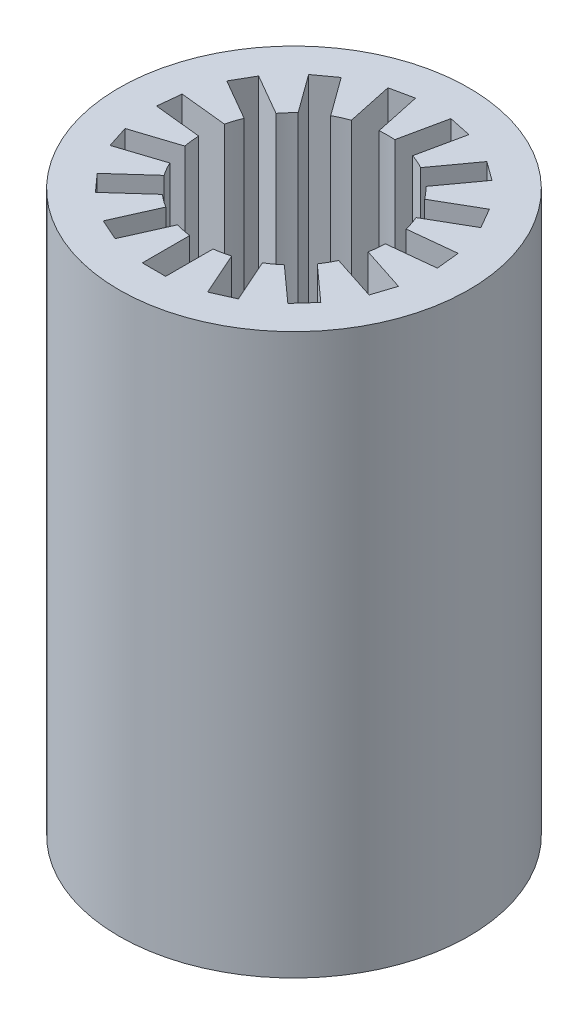
from build123d import *

# Parameters (mm, degrees)
SKETCH1_R           = 7.5
BOSS_EXTRUDE1_DEPTH = 24


with BuildPart() as part:
    # Sketch1 → Boss-Extrude1 (new body)
    with BuildSketch(Plane(origin=(0, 0, 0), x_dir=(1, 0, 0), z_dir=(0, 1, 0))):
        Circle(SKETCH1_R)
        with BuildLine():
            Line((-0.5, -3.968626967), (-0.5, -6))
            Line((-0.5, -6), (0.5, -6))
            Line((0.5, -6), (0.5, -3.968626967))
            ThreePointArc((0.5, -3.968626967), (0.831646763, -3.912590403), (1.157413281, -3.82888946))
            Line((1.157413281, -3.82888946), (1.98364713, -5.684641067))
            Line((1.98364713, -5.684641067), (2.897192587, -5.277904424))
            Line((2.897192587, -5.277904424), (2.070958739, -3.422152817))
            ThreePointArc((2.070958739, -3.422152817), (2.351141009, -3.236067977), (2.614699291, -3.027102181))
            Line((2.614699291, -3.027102181), (4.12430365, -4.386356051))
            Line((4.12430365, -4.386356051), (4.793434256, -3.643211225))
            Line((4.793434256, -3.643211225), (3.283829898, -2.283957356))
            ThreePointArc((3.283829898, -2.283957356), (3.464101615, -2), (3.61988004, -1.701901435))
            Line((3.61988004, -1.701901435), (5.551830601, -2.329630224))
            Line((5.551830601, -2.329630224), (5.860847595, -1.378573708))
            Line((5.860847595, -1.378573708), (3.928897035, -0.750844919))
            ThreePointArc((3.928897035, -0.750844919), (3.978087581, -0.418113853), (3.999150644, -0.08242647))
            Line((3.999150644, -0.08242647), (6.019395604, 0.129909832))
            Line((6.019395604, 0.129909832), (5.914867141, 1.124431727))
            Line((5.914867141, 1.124431727), (3.894622181, 0.912095426))
            ThreePointArc((3.894622181, 0.912095426), (3.804226065, 1.236067977), (3.686931771, 1.551300781))
            Line((3.686931771, 1.551300781), (5.446152423, 2.566987298))
            Line((5.446152423, 2.566987298), (4.946152423, 3.433012702))
            Line((4.946152423, 3.433012702), (3.186931771, 2.417326185))
            ThreePointArc((3.186931771, 2.417326185), (2.972579302, 2.676522425), (2.7372089, 2.916794034))
            Line((2.7372089, 2.916794034), (3.931220011, 4.56020934))
            Line((3.931220011, 4.56020934), (3.122203017, 5.147994592))
            Line((3.122203017, 5.147994592), (1.928191906, 3.504579286))
            ThreePointArc((1.928191906, 3.504579286), (1.626946572, 3.654181831), (1.314197743, 3.7779471))
            Line((1.314197743, 3.7779471), (1.736543945, 5.764929759))
            Line((1.736543945, 5.764929759), (0.758396345, 5.97284145))
            Line((0.758396345, 5.97284145), (0.336050142, 3.985858791))
            ThreePointArc((0.336050142, 3.985858791), (0, 4), (-0.336050142, 3.985858791))
            Line((-0.336050142, 3.985858791), (-0.758396345, 5.97284145))
            Line((-0.758396345, 5.97284145), (-1.736543945, 5.764929759))
            Line((-1.736543945, 5.764929759), (-1.314197743, 3.7779471))
            ThreePointArc((-1.314197743, 3.7779471), (-1.626946572, 3.654181831), (-1.928191906, 3.504579286))
            Line((-1.928191906, 3.504579286), (-3.122203017, 5.147994592))
            Line((-3.122203017, 5.147994592), (-3.931220011, 4.56020934))
            Line((-3.931220011, 4.56020934), (-2.7372089, 2.916794034))
            ThreePointArc((-2.7372089, 2.916794034), (-2.972579302, 2.676522425), (-3.186931771, 2.417326185))
            Line((-3.186931771, 2.417326185), (-4.946152423, 3.433012702))
            Line((-4.946152423, 3.433012702), (-5.446152423, 2.566987298))
            Line((-5.446152423, 2.566987298), (-3.686931771, 1.551300781))
            ThreePointArc((-3.686931771, 1.551300781), (-3.804226065, 1.236067977), (-3.894622181, 0.912095426))
            Line((-3.894622181, 0.912095426), (-5.914867141, 1.124431727))
            Line((-5.914867141, 1.124431727), (-6.019395604, 0.129909832))
            Line((-6.019395604, 0.129909832), (-3.999150644, -0.08242647))
            ThreePointArc((-3.999150644, -0.08242647), (-3.978087581, -0.418113853), (-3.928897035, -0.750844919))
            Line((-3.928897035, -0.750844919), (-5.860847595, -1.378573708))
            Line((-5.860847595, -1.378573708), (-5.551830601, -2.329630224))
            Line((-5.551830601, -2.329630224), (-3.61988004, -1.701901435))
            ThreePointArc((-3.61988004, -1.701901435), (-3.464101615, -2), (-3.283829898, -2.283957356))
            Line((-3.283829898, -2.283957356), (-4.793434256, -3.643211225))
            Line((-4.793434256, -3.643211225), (-4.12430365, -4.386356051))
            Line((-4.12430365, -4.386356051), (-2.614699291, -3.027102181))
            ThreePointArc((-2.614699291, -3.027102181), (-2.351141009, -3.236067977), (-2.070958739, -3.422152817))
            Line((-2.070958739, -3.422152817), (-2.897192587, -5.277904424))
            Line((-2.897192587, -5.277904424), (-1.98364713, -5.684641067))
            Line((-1.98364713, -5.684641067), (-1.157413281, -3.82888946))
            ThreePointArc((-1.157413281, -3.82888946), (-0.831646763, -3.912590403), (-0.5, -3.968626967))
        make_face(mode=Mode.SUBTRACT)
    extrude(amount=BOSS_EXTRUDE1_DEPTH)


solid = part.part
